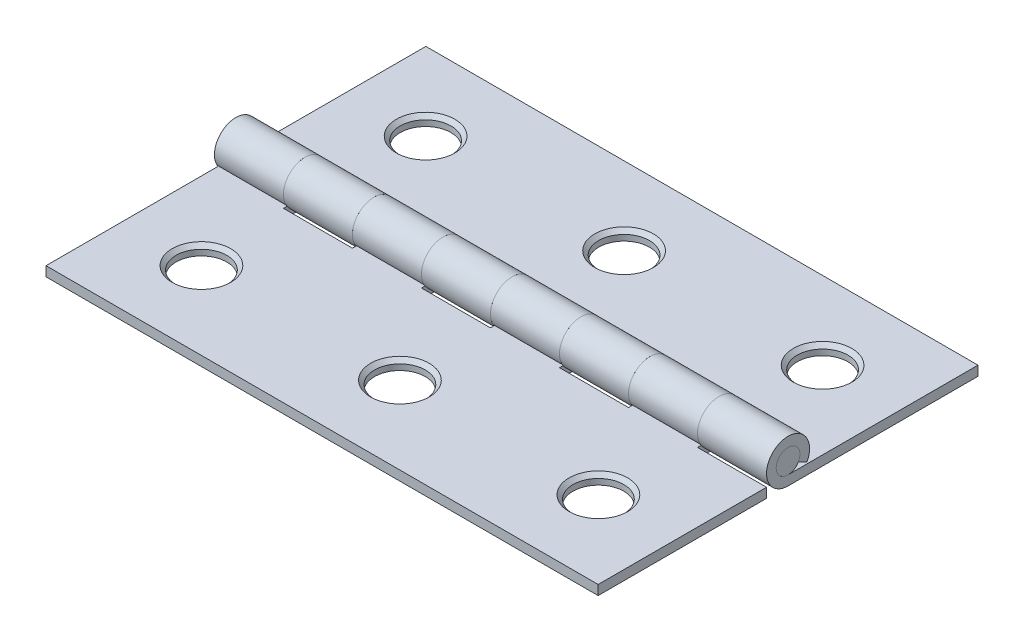
from build123d import *

# Parameters (mm, degrees)
BOSS_EXTRUDE1_DEPTH     = 25.4
SKETCH4_W               = 6.35
SKETCH4_H               = 3.9624
CUT_EXTRUDE1_DEPTH      = 2.9812
LPATTERN1_COUNT         = 6
LPATTERN1_PITCH         = 12.7
SKETCH5_R               = 2.6924
CUT_EXTRUDE2_DEPTH      = 1.889
CUT_EXTRUDE2_TAPER      = 45
SKETCH9_R               = 2.3368
CUT_EXTRUDE3_DEPTH      = 2.9812
CUT_EXTRUDE3_DEPTH_BACK = 2.9812001
CIRPATTERN1_COUNT       = 2
SKETCH6_R               = 1.0922
BOSS_EXTRUDE2_DEPTH     = 25.4


with BuildPart() as part:
    # Sketch3 → Boss-Extrude1 (new body, symmetric)
    with BuildSketch(Plane(origin=(0, 0, 0), x_dir=(0, 0, -1), z_dir=(1, 0, 0))):
        with BuildLine():
            Line((0, -1.9812), (-17.4752, -1.9812))
            Line((-17.4752, -1.9812), (-17.4752, -1.0922))
            Line((-17.4752, -1.0922), (0, -1.0922))
            ThreePointArc((0, -1.0922), (0.555423966, 0.940428125), (-0.956484745, -0.527292872))
            Line((-0.956484745, -0.527292872), (-1.735018839, -0.956484745))
            ThreePointArc((-1.735018839, -0.956484745), (1.007513242, 1.705892877), (0, -1.9812))
        make_face()
    extrude(amount=BOSS_EXTRUDE1_DEPTH, both=True)

    # Sketch4 → Cut-Extrude1 (cut, symmetric)
    with BuildSketch(Plane(origin=(0, 0, 0), x_dir=(1, 0, 0), z_dir=(0, 1, 0))):
        with Locations((-15.875, 0)):
            Rectangle(SKETCH4_W, SKETCH4_H)
    cut_extrude1 = extrude(amount=CUT_EXTRUDE1_DEPTH, both=True, mode=Mode.SUBTRACT)

    # LPattern1: Cut-Extrude1 ×6
    with Locations(*[(i * LPATTERN1_PITCH, 0, 0) for i in range(1, LPATTERN1_COUNT)]):
        add(cut_extrude1, mode=Mode.SUBTRACT)

    # Sketch5 → Cut-Extrude2 (cut, through all)
    with BuildSketch(Plane(origin=(0, -1.0922, 0), x_dir=(1, 0, 0), z_dir=(0, 1, 0))):
        with Locations((18.2626, -10.3124)):
            Circle(SKETCH5_R)
        with Locations((0, -10.3124)):
            Circle(SKETCH5_R)
        with Locations((-18.2626, -10.3124)):
            Circle(SKETCH5_R)
    extrude(amount=-CUT_EXTRUDE2_DEPTH, taper=CUT_EXTRUDE2_TAPER, mode=Mode.SUBTRACT)

    # Sketch9 → Cut-Extrude3 (cut, two sides)
    with BuildSketch(Plane(origin=(0, 0, 0), x_dir=(1, 0, 0), z_dir=(0, 1, 0))) as cut_extrude3_sk:
        with Locations((18.2626, -10.3124)):
            Circle(SKETCH9_R)
        with Locations((0, -10.3124)):
            Circle(SKETCH9_R)
        with Locations((-18.2626, -10.3124)):
            Circle(SKETCH9_R)
    extrude(amount=CUT_EXTRUDE3_DEPTH, mode=Mode.SUBTRACT)
    extrude(cut_extrude3_sk.sketch, amount=-CUT_EXTRUDE3_DEPTH_BACK, mode=Mode.SUBTRACT)


with BuildPart() as cirpattern1_1:
    # CirPattern1: pattern copy
    add(part.part.rotate(Axis((0, 0, 0), (0, 1, 0)), 1 * 360 / CIRPATTERN1_COUNT))


with BuildPart() as body_3:
    # Sketch6 → Boss-Extrude2 (new body, symmetric)
    with BuildSketch(Plane(origin=(0, 0, 0), x_dir=(0, 0, -1), z_dir=(1, 0, 0))):
        Circle(SKETCH6_R)
    extrude(amount=BOSS_EXTRUDE2_DEPTH, both=True)


solid = Compound([part.part, cirpattern1_1.part, body_3.part])
